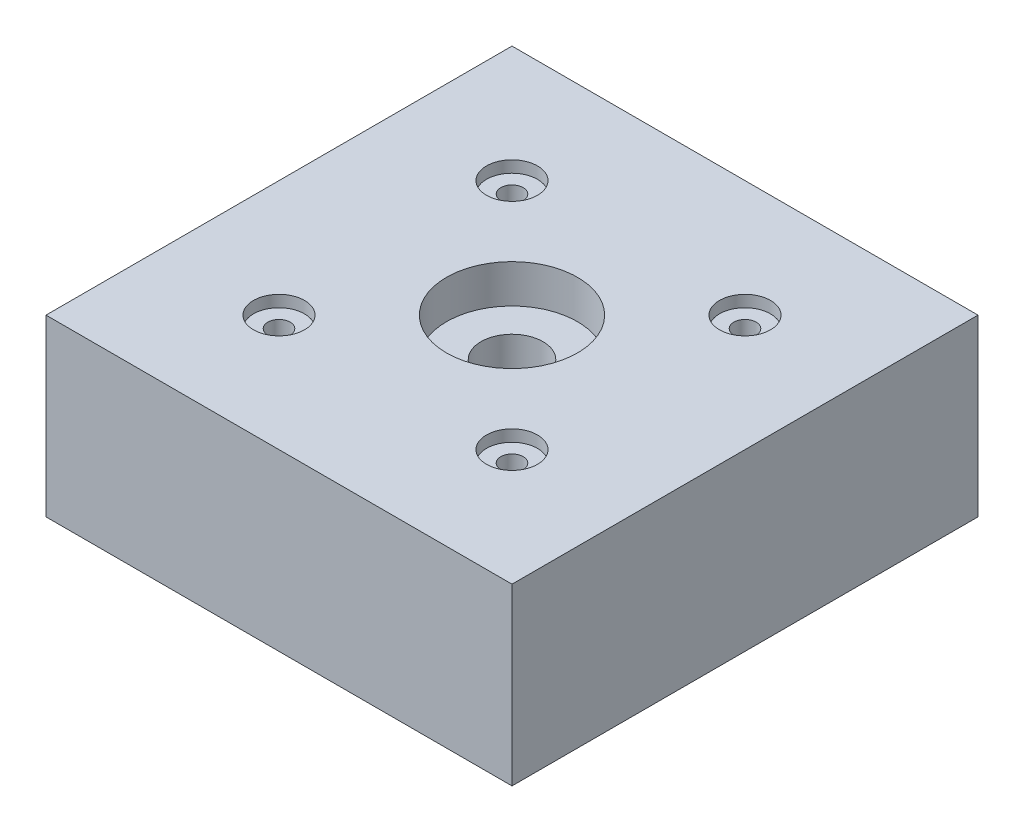
from build123d import *

# Parameters (mm, degrees)
SKETCH1_W                                            = 50.8
SKETCH1_H                                            = 50.8
BOSS_EXTRUDE1_DEPTH                                  = 19.05
CBORE_FOR_1_4_BINDING_HEAD_MACHINE_SCREW_D           = 6.7564
CBORE_FOR_1_4_BINDING_HEAD_MACHINE_SCREW_CBORE_D     = 14.2875
CBORE_FOR_1_4_BINDING_HEAD_MACHINE_SCREW_CBORE_DEPTH = 4.191
CBORE_FOR_2_BINDING_HEAD_MACHINE_SCREW1_D            = 2.4384
CBORE_FOR_2_BINDING_HEAD_MACHINE_SCREW1_CBORE_D      = 5.55752
CBORE_FOR_2_BINDING_HEAD_MACHINE_SCREW1_CBORE_DEPTH  = 1.27
CBORE_FOR_2_BINDING_HEAD_MACHINE_SCREW2_D            = 2.4384
CBORE_FOR_2_BINDING_HEAD_MACHINE_SCREW2_CBORE_D      = 5.55752
CBORE_FOR_2_BINDING_HEAD_MACHINE_SCREW2_CBORE_DEPTH  = 1.27


with BuildPart() as part:
    # Sketch1 → Boss-Extrude1 (new body)
    with BuildSketch(Plane(origin=(0, 0, 0), x_dir=(1, 0, 0), z_dir=(0, 1, 0))):
        Rectangle(SKETCH1_W, SKETCH1_H)
    extrude(amount=BOSS_EXTRUDE1_DEPTH)

    # CBORE for 1/4 Binding Head Machine Screw1 (through all)
    with Locations(Plane(origin=(0, 19.05, 0), x_dir=(1, 0, 0), z_dir=(0, 1, 0))):
        with Locations((0, 0)):
            CounterBoreHole(CBORE_FOR_1_4_BINDING_HEAD_MACHINE_SCREW_D / 2, CBORE_FOR_1_4_BINDING_HEAD_MACHINE_SCREW_CBORE_D / 2, CBORE_FOR_1_4_BINDING_HEAD_MACHINE_SCREW_CBORE_DEPTH)

    # CBORE for #2 Binding Head Machine Screw1 (through all)
    with Locations(Plane(origin=(0, 19.05, 0), x_dir=(1, 0, 0), z_dir=(0, 1, 0))):
        with Locations((-12.7, 12.7), (0, 0)):
            CounterBoreHole(CBORE_FOR_2_BINDING_HEAD_MACHINE_SCREW1_D / 2, CBORE_FOR_2_BINDING_HEAD_MACHINE_SCREW1_CBORE_D / 2, CBORE_FOR_2_BINDING_HEAD_MACHINE_SCREW1_CBORE_DEPTH)

    # CBORE for #2 Binding Head Machine Screw2 (through all)
    with Locations(Plane(origin=(0, 19.05, 0), x_dir=(1, 0, 0), z_dir=(0, 1, 0))):
        with Locations((12.7, 12.7), (-12.7, -12.7), (12.7, -12.7)):
            CounterBoreHole(CBORE_FOR_2_BINDING_HEAD_MACHINE_SCREW2_D / 2, CBORE_FOR_2_BINDING_HEAD_MACHINE_SCREW2_CBORE_D / 2, CBORE_FOR_2_BINDING_HEAD_MACHINE_SCREW2_CBORE_DEPTH)


solid = part.part
